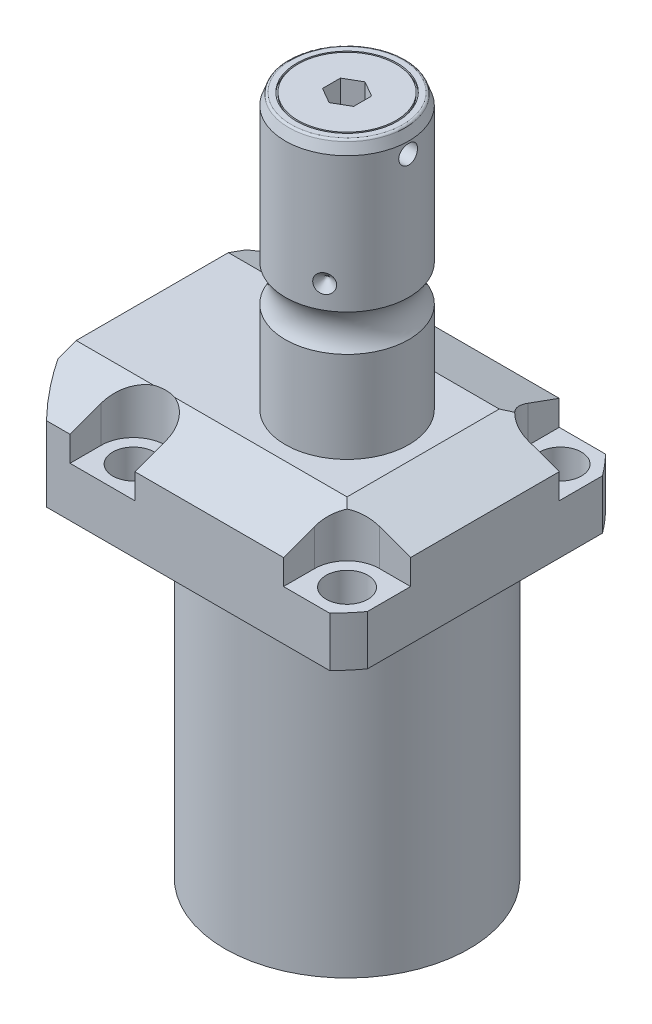
from build123d import *

# Parameters (mm, degrees)
SKETCH1_W               = 70.866
SKETCH1_H               = 85.496
EXTRUDE1_DEPTH          = 104.4448
SKETCH2_OUTSIDE_W       = 117.986
SKETCH2_OUTSIDE_H       = 103.356
SKETCH2_OUTSIDE_R       = 50.8
CUT_EXTRUDE1_DEPTH      = 105.4448
SKETCH3_W               = 45.1992
SKETCH3_H               = 79.4258
FILLET1_R               = 0.381
CUT_EXTRUDE2_DEPTH      = 12.243
CUT_EXTRUDE9_START      = -51.063
CUT_EXTRUDE9_DEPTH      = 87.496
CUT_EXTRUDE7_DEPTH      = 36.433
CUT_EXTRUDE7_DEPTH_BACK = 36.433
SKETCH10_R              = 1.1811
SKETCH17_W              = 5.3594
SKETCH17_H              = 12.776
HOLE1_AT_2_COUNT        = 2
HOLE1_AT_2_PITCH        = 54.864
HOLE1_AT_3_COUNT        = 2
HOLE1_AT_3_PITCH        = 77.589412886
HOLE1_AT_4_COUNT        = 2
HOLE1_AT_4_PITCH        = 54.864
CHAMFER1_SIZE           = 0.635
SKETCH22_R              = 6.35
EXTRUDE2_DEPTH          = 1.651
FILLET2_R               = 0.635
SKETCH24_R              = 12.954
SKETCH24_R_2            = 12.573
CUT_EXTRUDE10_DEPTH     = 0.49999999
CUT_EXTRUDE11_DEPTH     = 8
CIRPATTERN1_COUNT       = 3
SKETCH27_W              = 3.81
SKETCH27_H              = 2.413
CHAMFER2_SIZE           = 1.016


with BuildPart() as part:
    # Sketch1 → Extrude1 (new body)
    with BuildSketch(Plane(origin=(0, 0, 0), x_dir=(0, 0, 1), z_dir=(0, -1, 0))):
        with Locations((0, 7.315)):
            Rectangle(SKETCH1_W, SKETCH1_H)
    extrude(amount=-EXTRUDE1_DEPTH)

    # Sketch2 outside → Cut-Extrude1 (cut, through all)
    with BuildSketch(Plane.XZ):
        with Locations((-7.315, 0)):
            Rectangle(SKETCH2_OUTSIDE_W, SKETCH2_OUTSIDE_H)
        with Locations((-5.4102, 0)):
            Circle(SKETCH2_OUTSIDE_R, mode=Mode.SUBTRACT)
    extrude(amount=-CUT_EXTRUDE1_DEPTH, mode=Mode.SUBTRACT)

    # Sketch3 → Cut-Revolve1 (revolve, cut)
    with BuildSketch(Plane(origin=(0, 0, 0), x_dir=(0, 0, -1), z_dir=(1, 0, 0))):
        with Locations((53.9941, 39.7129)):
            Rectangle(SKETCH3_W, SKETCH3_H)
    revolve(axis=Axis((0, -93.345, 0), (0, 1, 0)), mode=Mode.SUBTRACT)

    # Fillet1
    fillet1_edges = [part.edges().sort_by_distance(p)[0] for p in [
        (0, 79.4258, 31.3945),
    ]]
    fillet(fillet1_edges, radius=FILLET1_R)

    # Sketch4 → Cut-Extrude2 (cut)
    with BuildSketch(Plane(origin=(0, 104.4448, 0), x_dir=(-1, 0, 0), z_dir=(0, 1, 0))):
        with BuildLine():
            Line((-19.1008, -35.433), (-19.1008, -27.432))
            ThreePointArc((-19.1008, -27.432), (-21.540951985, -21.540951985), (-27.432, -19.1008))
            Line((-27.432, -19.1008), (-35.433, -19.1008))
            Line((-35.433, -19.1008), (-35.433, -35.433))
            Line((-35.433, -35.433), (-19.1008, -35.433))
        make_face()
        with BuildLine():
            Line((35.7632, -35.433), (19.1008, -35.433))
            Line((19.1008, -35.433), (19.1008, -27.432))
            ThreePointArc((19.1008, -27.432), (27.432, -19.1008), (35.7632, -27.432))
            Line((35.7632, -27.432), (35.7632, -35.433))
        make_face()
        with BuildLine():
            Line((19.1008, 35.433), (19.1008, 27.432))
            ThreePointArc((19.1008, 27.432), (27.432, 19.1008), (35.7632, 27.432))
            Line((35.7632, 27.432), (35.7632, 35.433))
            Line((35.7632, 35.433), (19.1008, 35.433))
        make_face()
        with BuildLine():
            Line((-27.432, 19.1008), (-35.433, 19.1008))
            Line((-35.433, 19.1008), (-35.433, 35.433))
            Line((-35.433, 35.433), (-19.1008, 35.433))
            Line((-19.1008, 35.433), (-19.1008, 27.432))
            ThreePointArc((-19.1008, 27.432), (-21.540951985, 21.540951985), (-27.432, 19.1008))
        make_face()
    extrude(amount=-CUT_EXTRUDE2_DEPTH, mode=Mode.SUBTRACT)

    # Sketch5 → Cut-Extrude9 (cut)
    with BuildSketch(Plane(origin=(0, 0, 0), x_dir=(0, 0, -1), z_dir=(1, 0, 0)).offset(CUT_EXTRUDE9_START)):
        Polygon((-19.558, 104.4448), (-35.433, 98.666772531), (-35.433, 104.4448), align=None)
    cut_extrude9 = extrude(amount=CUT_EXTRUDE9_DEPTH, mode=Mode.SUBTRACT)

    # Mirror1: Cut-Extrude9 across plane
    add(cut_extrude9.mirror(Plane.XY), mode=Mode.SUBTRACT)

    # Sketch9 → Cut-Extrude7 (cut, two sides)
    with BuildSketch(Plane.XY) as cut_extrude7_sk:
        Polygon((19.558, 104.4448), (35.433, 98.666772531), (35.433, 104.4448), align=None)
    extrude(amount=CUT_EXTRUDE7_DEPTH, mode=Mode.SUBTRACT)
    extrude(cut_extrude7_sk.sketch, amount=-CUT_EXTRUDE7_DEPTH_BACK, mode=Mode.SUBTRACT)

    # Sketch20 → Cut-Revolve4 (revolve, cut)
    with BuildSketch(Plane(origin=(-35.0774, 88.9, -18.1102), x_dir=(0, 1, 0), z_dir=(1, 0, 0)), mode=Mode.PRIVATE) as cut_revolve4_sk:
        Polygon((-9.4742, 38.3413), (-8.0264, 38.3413), (-8.0264, 35.8902), (-7.0104, 35.8902), (-7.0104, 33.8836), (3.9624, 33.8836), (3.9624, 32.639), (-9.4742, 32.639), align=None)
    cut_revolve4 = revolve(cut_revolve4_sk.sketch.rotate(Axis((-35.0774, 81.620304954, 14.5288), (0, 1, 0)), 180), axis=Axis((-35.0774, 81.620304954, 14.5288), (0, 1, 0)), mode=Mode.SUBTRACT)  # turned: the seam where the file's is

    # Mirror10: Cut-Revolve4 across plane
    add(cut_revolve4.mirror(Plane.XY), mode=Mode.SUBTRACT)

    # Sketch15 → Revolve3 (revolve)
    with BuildSketch(Plane(origin=(0, 0, 0), x_dir=(0, 0, -1), z_dir=(1, 0, 0)), mode=Mode.PRIVATE) as revolve3_sk:
        with BuildLine():
            Line((0, 104.4448), (15.875, 104.4448))
            Line((15.875, 104.4448), (15.875, 127.82870643))
            ThreePointArc((15.875, 127.82870643), (14.3256, 132.5358), (15.875, 137.24289357))
            Line((15.875, 137.24289357), (15.875, 172.03279416))
            Line((15.875, 172.03279416), (14.81184082, 174.9538))
            Line((14.81184082, 174.9538), (0, 174.9538))
            Line((0, 174.9538), (0, 104.4448))
        make_face()
    revolve(revolve3_sk.sketch.rotate(Axis((0, 250.290824608, 0), (0, -1, 0)), 180), axis=Axis((0, 250.290824608, 0), (0, -1, 0)))  # turned: the seam where the file's is

    # Sketch17 → Hole1 (revolve, cut)
    with BuildSketch(Plane(origin=(27.432, 92.2018, -27.432), x_dir=(0, 0, 1), z_dir=(1, 0, 0))):
        with Locations((2.6797, 6.388)):
            Rectangle(SKETCH17_W, SKETCH17_H)
    hole1 = revolve(axis=Axis((27.432, -17.7982, -27.432), (0, 1, 0)), mode=Mode.SUBTRACT)

    # Hole1 at 2: Hole1 ×2
    with Locations(*[(0, 0, i * HOLE1_AT_2_PITCH) for i in range(1, HOLE1_AT_2_COUNT)]):
        add(hole1, mode=Mode.SUBTRACT)

    # Hole1 at 3: Hole1 ×2
    with Locations(*[Vector(-0.707106781, 0, 0.707106781) * (i * HOLE1_AT_3_PITCH) for i in range(1, HOLE1_AT_3_COUNT)]):
        add(hole1, mode=Mode.SUBTRACT)

    # Hole1 at 4: Hole1 ×2
    with Locations(*[(-i * HOLE1_AT_4_PITCH, 0, 0) for i in range(1, HOLE1_AT_4_COUNT)]):
        add(hole1, mode=Mode.SUBTRACT)

    # Chamfer1
    chamfer1_edges = [part.edges().sort_by_distance(p)[0] for p in [
        (-35.0774, 81.8896, 15.7734),
        (-35.0774, 81.8896, -15.7734),
    ]]
    chamfer(chamfer1_edges, length=CHAMFER1_SIZE)

    # Sketch21 → Cut-Revolve5 (revolve, cut)
    with BuildSketch(Plane.XZ.offset(-91.9226)):
        Polygon((-50.063, -2.5019), (-49.809, -2.5019), (-49.809, -6.7564), (-47.2563, -7.440393904), (-46.695693904, -8.001), (-30.759, -8.001), (-30.759, -12.9794), (-50.063, -12.9794), align=None)
    cut_revolve5 = revolve(axis=Axis((-57.549532301, 91.9226, -12.9794), (1, 0, 0)), mode=Mode.SUBTRACT)

    # Mirror13: Cut-Revolve5 across plane
    add(cut_revolve5.mirror(Plane.XY), mode=Mode.SUBTRACT)

    # Sketch22 → Extrude2 (add)
    with BuildSketch(Plane.ZY.offset(49.809)):
        with Locations((-12.9794, 91.9226)):
            Circle(SKETCH22_R)
    extrude(amount=EXTRUDE2_DEPTH)

    # Fillet2
    fillet2_edges = [part.edges().sort_by_distance(p)[0] for p in [
        (0, 174.9538, -14.81184082),
    ]]
    fillet(fillet2_edges, radius=FILLET2_R)

    # Sketch24 → Cut-Extrude10 (cut)
    with BuildSketch(Plane(origin=(0, 174.9538, 0), x_dir=(1, 0, 0), z_dir=(0, 1, 0))):
        with Locations(Location((0, 0, 0), (0, 0, 270))):  # turned: the seam where the file's is
            Circle(SKETCH24_R)
        with Locations(Location((0, 0, 0), (0, 0, 270))):  # turned: the seam where the file's is
            Circle(SKETCH24_R_2, mode=Mode.SUBTRACT)
    extrude(amount=-CUT_EXTRUDE10_DEPTH, mode=Mode.SUBTRACT)

    # Sketch25 → Cut-Extrude11 (cut)
    with BuildSketch(Plane(origin=(0, 174.9538, 0), x_dir=(1, 0, 0), z_dir=(0, 1, 0))):
        Polygon((4, -2.309401077), (4, 2.309401077), (0, 4.618802154), (-4, 2.309401077), (-4, -2.309401077), (0, -4.618802154), align=None)
    extrude(amount=-CUT_EXTRUDE11_DEPTH, mode=Mode.SUBTRACT)

    # Sketch26 → Cut-Revolve7 (revolve, cut)
    with BuildSketch(Plane.XY, mode=Mode.PRIVATE) as cut_revolve7_sk:
        Polygon((-15.875, 145.6168), (-13.462, 143.2038), (-15.875, 143.2038), align=None)
    cut_revolve7 = revolve(cut_revolve7_sk.sketch.rotate(Axis((-39.772000707, 143.2038, 0), (1, 0, 0)), 90), axis=Axis((-39.772000707, 143.2038, 0), (1, 0, 0)), mode=Mode.SUBTRACT)  # turned: the seam where the file's is

    # CirPattern1: Cut-Revolve7 ×3 about axis
    cirpattern1_axis = Axis((0, 250.290824608, 0), (0, 1, 0))
    for i in range(1, CIRPATTERN1_COUNT):
        add(cut_revolve7.rotate(cirpattern1_axis, i * 360 / CIRPATTERN1_COUNT), mode=Mode.SUBTRACT)

    # Sketch27 → Cut-Revolve8 (revolve, cut)
    with BuildSketch(Plane.XY, mode=Mode.PRIVATE) as cut_revolve8_sk:
        with Locations((13.97, 170.3183)):
            Rectangle(SKETCH27_W, SKETCH27_H)
    revolve(cut_revolve8_sk.sketch.rotate(Axis((5.37407372, 169.1118, 0), (1, 0, 0)), 90), axis=Axis((5.37407372, 169.1118, 0), (1, 0, 0)), mode=Mode.SUBTRACT)  # turned: the seam where the file's is

    # Chamfer2
    chamfer2_edges = [part.edges().sort_by_distance(p)[0] for p in [
        (-51.46, 91.9226, -19.3294),
    ]]
    chamfer(chamfer2_edges, length=CHAMFER2_SIZE)


with BuildPart() as body_2:
    # Sketch10 → Revolve4 (revolve)
    with BuildSketch(Plane(origin=(-35.0774, 88.9, -18.1102), x_dir=(0, 1, 0), z_dir=(1, 0, 0))):
        with Locations((-9.2075, 8.1026)):
            Circle(SKETCH10_R)
    revolve(axis=Axis((-35.0774, 87.86749, -14.5288), (0, 1, 0)))


with BuildPart() as body_3:
    # Mirror12: mirrored copy
    add(body_2.part.mirror(Plane.XY))


solid = Compound([part.part, body_2.part, body_3.part])
